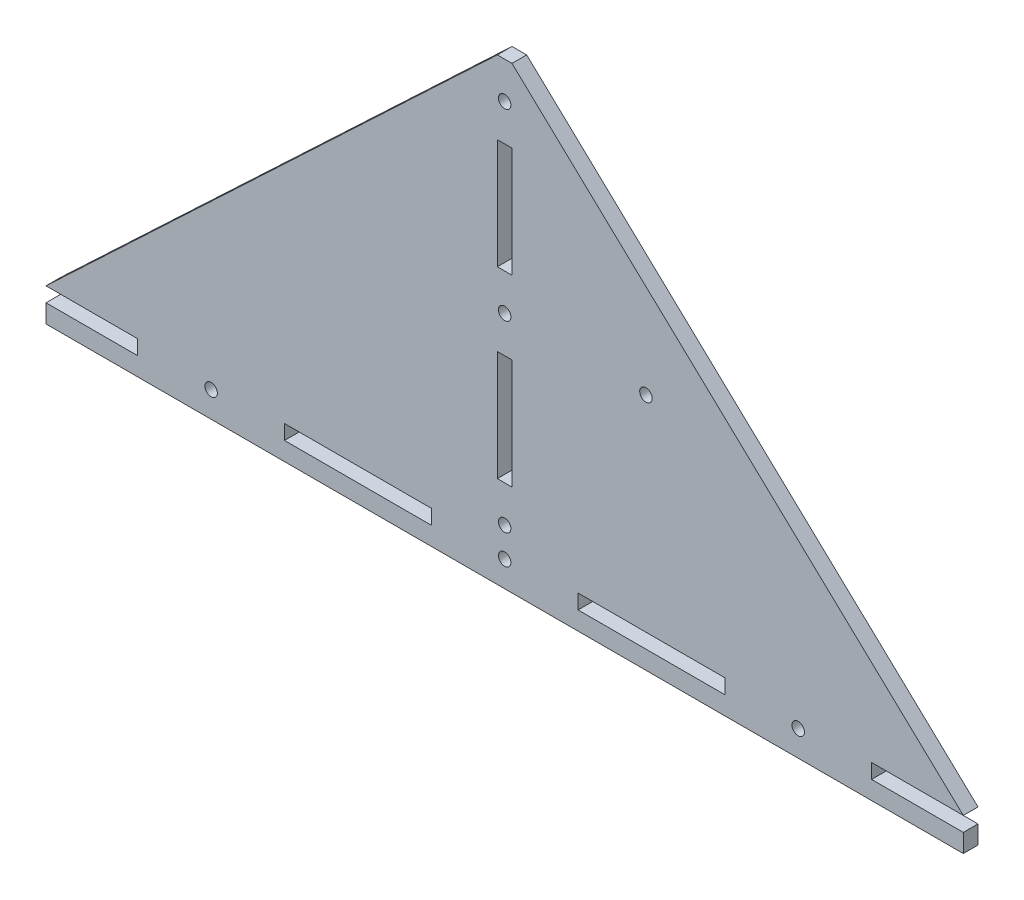
from build123d import *

# Parameters (mm, degrees)
BOSS_EXTRU_1_DEPTH         = 4
ESQUISSE2_W                = 4
ESQUISSE2_H                = 30
ENL_V_MAT_EXTRU_1_DEPTH    = 4
R_P_TITION_LIN_AIRE1_COUNT = 2
R_P_TITION_LIN_AIRE1_PITCH = 50
ESQUISSE3_W                = 25
ESQUISSE3_H                = 4
ESQUISSE3_W_2              = 40
ENL_V_MAT_EXTRU_2_DEPTH    = 4
D_GAGEMENT_M31_D           = 3.4
ESQUISSE9_W                = 250
ESQUISSE9_H                = 4
BOSS_EXTRU_2_DEPTH         = 5
ESQUISSE10_R               = 1.7
ENL_V_MAT_EXTRU_3_DEPTH    = 10


with BuildPart() as part:
    # Esquisse1 → Boss.-Extru.1 (new body)
    with BuildSketch(Plane.XY):
        Polygon((-8.256647574, 32.690679855), (-4.256647574, 32.690679855), (118.743352426, -83.309320145), (118.743352426, -87.309320145), (-131.256647574, -87.309320145), (-131.256647574, -83.309320145), align=None)
    extrude(amount=BOSS_EXTRU_1_DEPTH)

    # Esquisse2 → Enlèv. mat.-Extru.1 (cut)
    with BuildSketch(Plane.XY.offset(4)):
        with Locations((-6.256647574, -2.309320145)):
            Rectangle(ESQUISSE2_W, ESQUISSE2_H)
    enl_v_mat_extru_1 = extrude(amount=-ENL_V_MAT_EXTRU_1_DEPTH, mode=Mode.SUBTRACT)

    # Répétition linéaire1: Enlèv. mat.-Extru.1 ×2
    with Locations(*[(0, -i * R_P_TITION_LIN_AIRE1_PITCH, 0) for i in range(1, R_P_TITION_LIN_AIRE1_COUNT)]):
        add(enl_v_mat_extru_1, mode=Mode.SUBTRACT)

    # Esquisse3 → Enlèv. mat.-Extru.2 (cut)
    with BuildSketch(Plane.XY.offset(4)):
        with Locations((-118.756647574, -85.309320145)):
            Rectangle(ESQUISSE3_W, ESQUISSE3_H)
        with Locations((33.743352426, -85.309320145)):
            Rectangle(ESQUISSE3_W_2, ESQUISSE3_H)
        with Locations((-46.256647574, -85.309320145)):
            Rectangle(ESQUISSE3_W_2, ESQUISSE3_H)
        with Locations((113.743352426, -85.309320145)):
            Rectangle(ESQUISSE3_W_2, ESQUISSE3_H)
    extrude(amount=-ENL_V_MAT_EXTRU_2_DEPTH, mode=Mode.SUBTRACT)

    # Dégagement M31 (through all)
    with Locations(Plane.XY.offset(4)):
        with Locations((-6.256647574, 22.690679855), (-6.256647574, -27.309320145), (-6.256647574, -77.309320145), (-6.256647574, -85.309320145), (-86.256647574, -85.309320145), (73.743352426, -85.309320145)):
            Hole(D_GAGEMENT_M31_D / 2)

    # Esquisse9 → Boss.-Extru.2 (add)
    with BuildSketch(Plane.XZ.offset(87.309320145)):
        with Locations((-6.256647574, 2)):
            Rectangle(ESQUISSE9_W, ESQUISSE9_H)
    extrude(amount=BOSS_EXTRU_2_DEPTH)

    # Esquisse10 → Enlèv. mat.-Extru.3 (cut)
    with BuildSketch(Plane(origin=(-276.256647574, 4.324322261, 4), x_dir=(1, 0, 0), z_dir=(0, 0, 1))):
        with Locations((308.5, -31.633642405)):
            Circle(ESQUISSE10_R)
    extrude(amount=-ENL_V_MAT_EXTRU_3_DEPTH, mode=Mode.SUBTRACT)


solid = part.part
